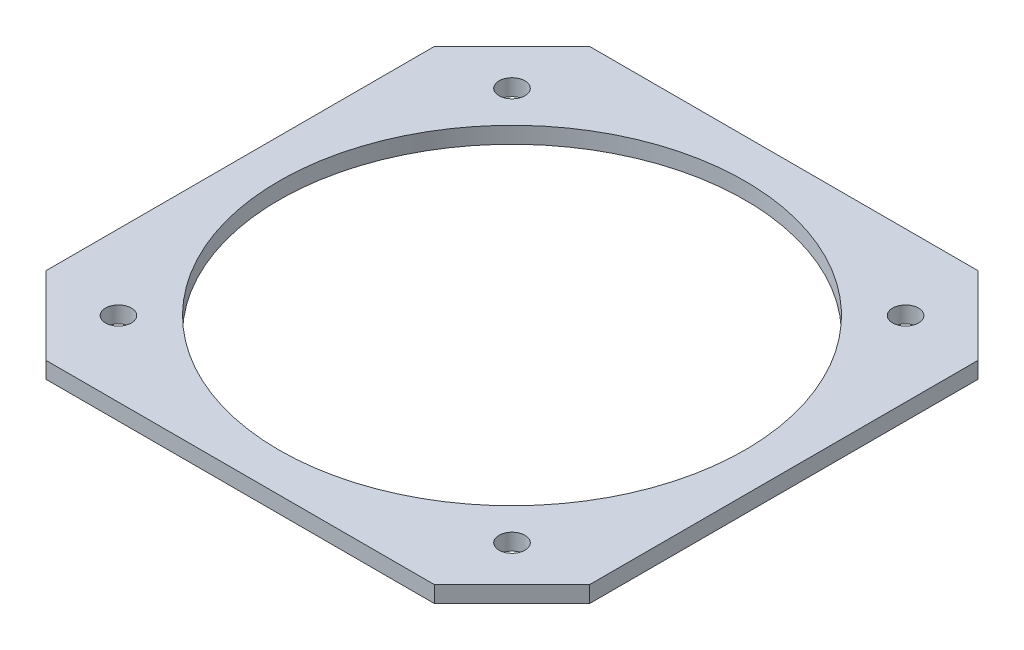
from build123d import *

# Parameters (mm, degrees)
SKETCH1_W           = 210
SKETCH1_H           = 210
SKETCH1_R           = 90
SKETCH1_R_2         = 5
BOSS_EXTRUDE1_DEPTH = 6.35
CHAMFER1_SIZE       = 30


with BuildPart() as part:
    # Sketch1 → Boss-Extrude1 (new body)
    with BuildSketch(Plane(origin=(0, 0, 0), x_dir=(1, 0, 0), z_dir=(0, 1, 0))):
        Rectangle(SKETCH1_W, SKETCH1_H)
        Circle(SKETCH1_R, mode=Mode.SUBTRACT)
        with Locations((-76.013978978, 76.013978978)):
            Circle(SKETCH1_R_2, mode=Mode.SUBTRACT)
        with Locations((76.013978978, 76.013978978)):
            Circle(SKETCH1_R_2, mode=Mode.SUBTRACT)
        with Locations((76.013978978, -76.013978978)):
            Circle(SKETCH1_R_2, mode=Mode.SUBTRACT)
        with Locations((-76.013978978, -76.013978978)):
            Circle(SKETCH1_R_2, mode=Mode.SUBTRACT)
    extrude(amount=BOSS_EXTRUDE1_DEPTH)

    # Chamfer1
    chamfer1_edges = [part.edges().sort_by_distance(p)[0] for p in [
        (105, 3.175, 105),
        (-105, 3.175, 105),
        (-105, 3.175, -105),
        (105, 3.175, -105),
    ]]
    chamfer(chamfer1_edges, length=CHAMFER1_SIZE)


solid = part.part
